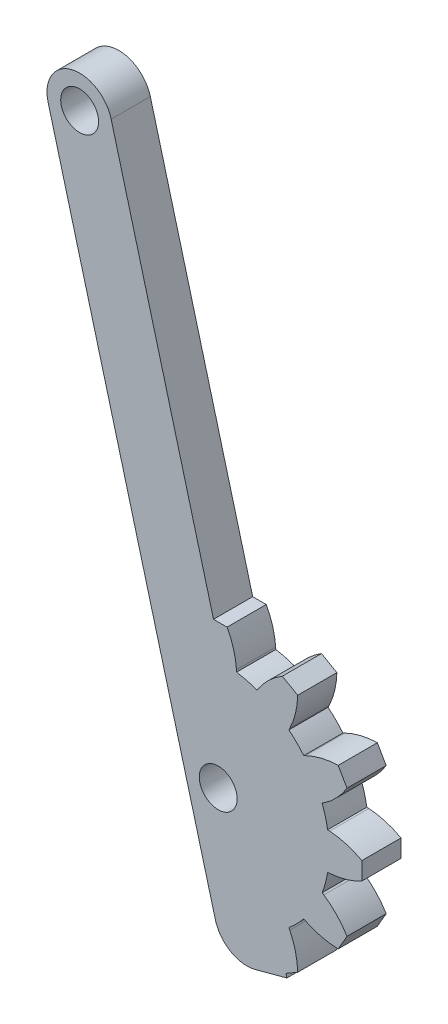
from build123d import *

# Parameters (mm, degrees)
SKETCH1_R           = 1.45
BOSS_EXTRUDE1_DEPTH = 3


with BuildPart() as part:
    # Sketch1 → Boss-Extrude1 (new body)
    with BuildSketch(Plane.XY.offset(1.9)):
        with BuildLine():
            Line((-13.026395415, 38.955911265), (-0.214852682, -8.857417136))
            ThreePointArc((-0.214852682, -8.857417136), (0.949961883, -10.375433033), (2.847009496, -10.625184089))
            Line((2.847009496, -10.625184089), (5.261824062, -9.978136476))
            Line((5.261824062, -9.978136476), (5.188879797, -9.705904774))
            Line((5.188879797, -9.705904774), (6.08761429, -9.187020173))
            ThreePointArc((6.08761429, -9.187020173), (5.919814799, -7.906537121), (5.481893659, -6.691622066))
            Line((5.481893659, -6.691622066), (5.414116812, -6.552658937))
            ThreePointArc((5.414116812, -6.552658937), (6.01040764, -6.01040764), (6.552658937, -5.414116812))
            Line((6.552658937, -5.414116812), (6.691622066, -5.481893659))
            ThreePointArc((6.691622066, -5.481893659), (7.906537121, -5.919814799), (9.187020173, -6.08761429))
            Line((9.187020173, -6.08761429), (9.86553871, -4.91238571))
            ThreePointArc((9.86553871, -4.91238571), (9.079978562, -3.887354604), (8.093270203, -3.054167872))
            Line((8.093270203, -3.054167872), (7.965092167, -2.967710696))
            ThreePointArc((7.965092167, -2.967710696), (8.210369523, -2.199961883), (8.381827508, -1.41243323))
            Line((8.381827508, -1.41243323), (8.536061531, -1.401648137))
            ThreePointArc((8.536061531, -1.401648137), (9.807169402, -1.173441441), (11, -0.678518537))
            Line((11, -0.678518537), (11, 0.678518537))
            ThreePointArc((11, 0.678518537), (9.807169402, 1.173441441), (8.536061531, 1.401648137))
            Line((8.536061531, 1.401648137), (8.381827508, 1.41243323))
            ThreePointArc((8.381827508, 1.41243323), (8.210369523, 2.199961883), (7.965092167, 2.967710696))
            Line((7.965092167, 2.967710696), (8.093270203, 3.054167872))
            ThreePointArc((8.093270203, 3.054167872), (9.079978562, 3.887354604), (9.86553871, 4.91238571))
            Line((9.86553871, 4.91238571), (9.187020173, 6.08761429))
            ThreePointArc((9.187020173, 6.08761429), (7.906537121, 5.919814799), (6.691622066, 5.481893659))
            Line((6.691622066, 5.481893659), (6.552658937, 5.414116812))
            ThreePointArc((6.552658937, 5.414116812), (6.01040764, 6.01040764), (5.414116812, 6.552658937))
            Line((5.414116812, 6.552658937), (5.481893659, 6.691622066))
            ThreePointArc((5.481893659, 6.691622066), (5.919814799, 7.906537121), (6.08761429, 9.187020173))
            Line((6.08761429, 9.187020173), (4.91238571, 9.86553871))
            ThreePointArc((4.91238571, 9.86553871), (3.887354604, 9.079978562), (3.054167872, 8.093270203))
            Line((3.054167872, 8.093270203), (2.967710696, 7.965092167))
            ThreePointArc((2.967710696, 7.965092167), (2.199961883, 8.210369523), (1.41243323, 8.381827508))
            Line((1.41243323, 8.381827508), (1.401648136, 8.536061531))
            ThreePointArc((1.401648136, 8.536061531), (1.173441441, 9.807169402), (0.678518537, 11))
            Line((0.678518537, 11), (-0.359250666, 11))
            Line((-0.359250666, 11), (-8.196766283, 40.250006491))
            ThreePointArc((-8.196766283, 40.250006491), (-11.258628462, 42.017773444), (-13.026395415, 38.955911265))
        make_face()
        with Locations((-10.611580849, 39.602958878)):
            Circle(SKETCH1_R, mode=Mode.SUBTRACT)
        Circle(SKETCH1_R, mode=Mode.SUBTRACT)
    extrude(amount=-BOSS_EXTRUDE1_DEPTH)


solid = part.part
